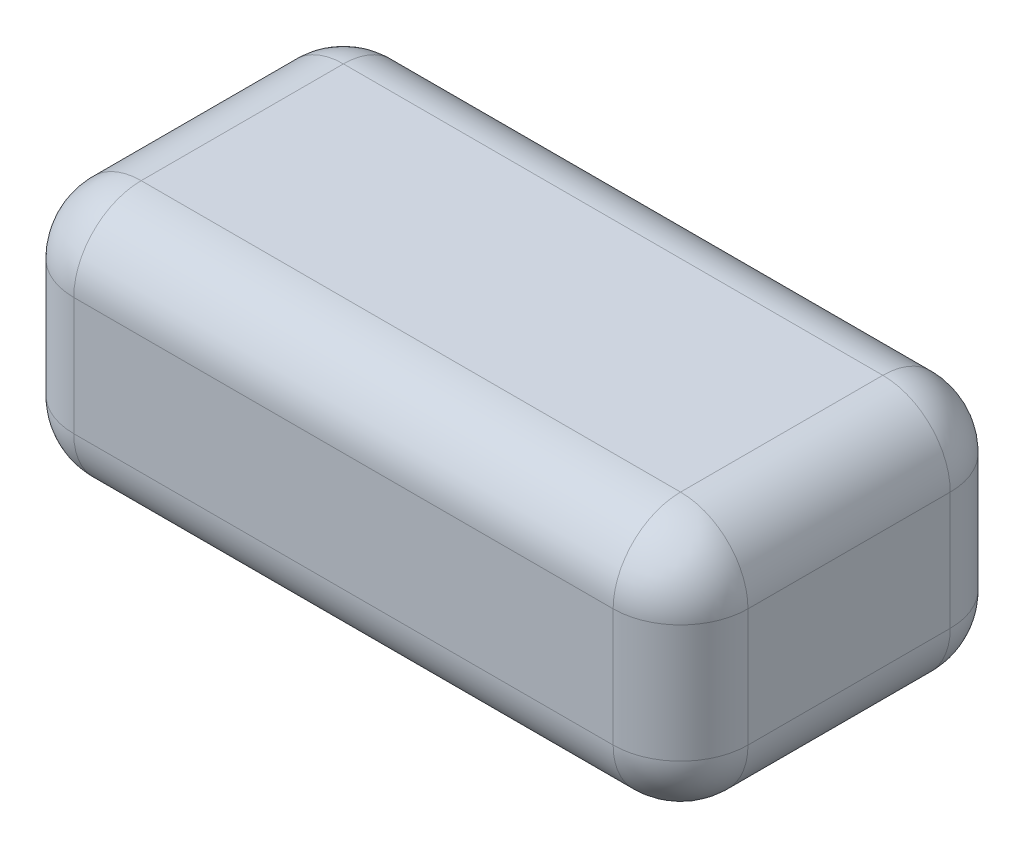
from build123d import *

# Parameters (mm, degrees)
SKETCH1_W           = 200
SKETCH1_H           = 100
BOSS_EXTRUDE1_DEPTH = 75
FILLET1_R           = 20


with BuildPart() as part:
    # Sketch1 → Boss-Extrude1 (new body)
    with BuildSketch(Plane(origin=(0, 0, 0), x_dir=(1, 0, 0), z_dir=(0, 1, 0))):
        Rectangle(SKETCH1_W, SKETCH1_H)
    extrude(amount=BOSS_EXTRUDE1_DEPTH)

    # Fillet1
    fillet1_edges = [part.edges().sort_by_distance(p)[0] for p in [
        (-100, 75, 0),
        (0, 75, 50),
        (100, 75, 0),
        (0, 0, 50),
        (-100, 0, 0),
        (0, 0, -50),
        (100, 0, 0),
        (100, 37.5, 50),
        (-100, 37.5, 50),
        (-100, 37.5, -50),
        (100, 37.5, -50),
        (0, 75, -50),
    ]]
    fillet(fillet1_edges, radius=FILLET1_R)


solid = part.part
